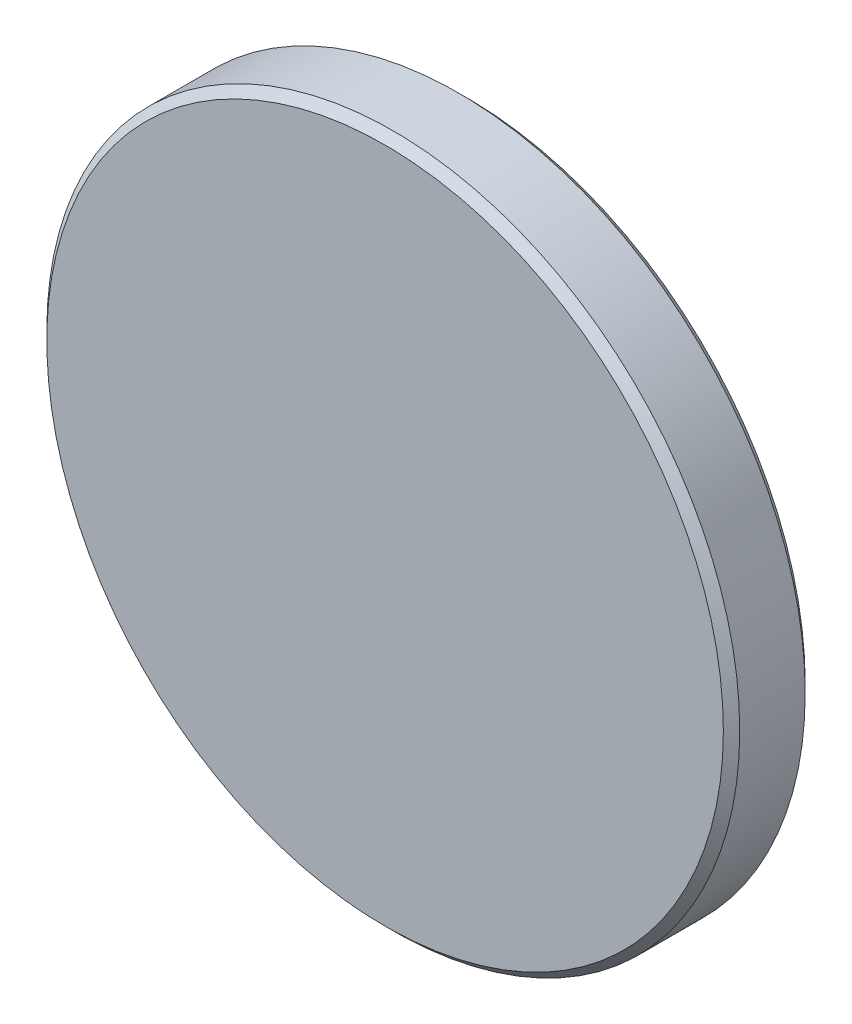
from build123d import *

# Parameters (mm, degrees)
SKETCH_1_R      = 12.7
EXTRUDE_1_DEPTH = 3
CHAMFER_1_SIZE  = 0.3


with BuildPart() as part:
    # 草图1 → 凸台-拉伸1 (new body)
    with BuildSketch(Plane.XY):
        Circle(SKETCH_1_R)
    extrude(amount=EXTRUDE_1_DEPTH)

    # 倒角1
    chamfer_1_edges = [part.edges().sort_by_distance(p)[0] for p in [
        (-12.7, 0, 0),
        (-12.7, 0, 3),
    ]]
    chamfer(chamfer_1_edges, length=CHAMFER_1_SIZE)


solid = part.part
